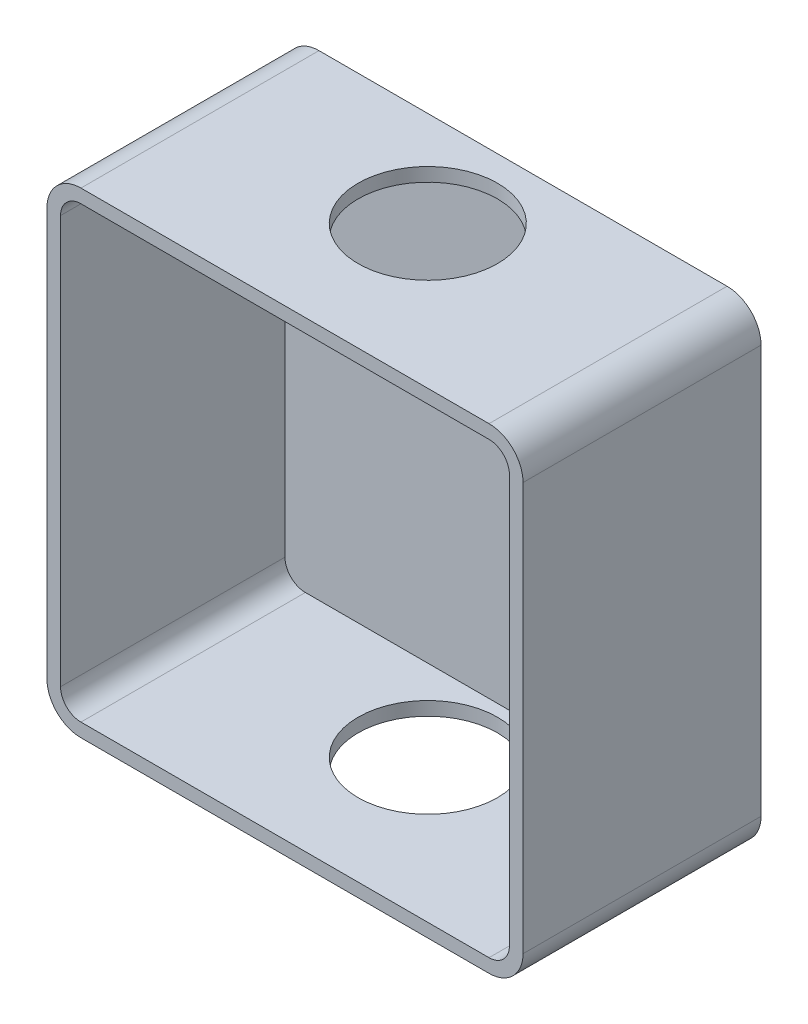
from build123d import *

# Parameters (mm, degrees)
AUFSATZ_LINEAR_AUSTRAGEN1_DEPTH = 35
WANDUNG1_T                      = -2
SKIZZE2_R                       = 10.25
SCHNITT_LINEAR_AUSTRAGEN1_DEPTH = 71


with BuildPart() as part:
    # Skizze1 → Aufsatz-Linear austragen1 (new body)
    with BuildSketch(Plane.XY):
        with BuildLine():
            Line((-30, -35), (30, -35))
            ThreePointArc((30, -35), (33.535533906, -33.535533906), (35, -30))
            Line((35, -30), (35, 30))
            ThreePointArc((35, 30), (33.535533906, 33.535533906), (30, 35))
            Line((30, 35), (-30, 35))
            ThreePointArc((-30, 35), (-33.535533906, 33.535533906), (-35, 30))
            Line((-35, 30), (-35, -30))
            ThreePointArc((-35, -30), (-33.535533906, -33.535533906), (-30, -35))
        make_face()
    extrude(amount=AUFSATZ_LINEAR_AUSTRAGEN1_DEPTH)

    # Wandung1
    wandung1_openings = [part.faces().sort_by_distance(p)[0] for p in [
        (0, 0, 35),
    ]]
    offset(amount=WANDUNG1_T, openings=wandung1_openings, kind=Kind.INTERSECTION)

    # Skizze2 → Schnitt-Linear austragen1 (cut, through all)
    with BuildSketch(Plane.XZ.offset(35)):
        with Locations((0, 14)):
            Circle(SKIZZE2_R)
    extrude(amount=-SCHNITT_LINEAR_AUSTRAGEN1_DEPTH, mode=Mode.SUBTRACT)


solid = part.part
